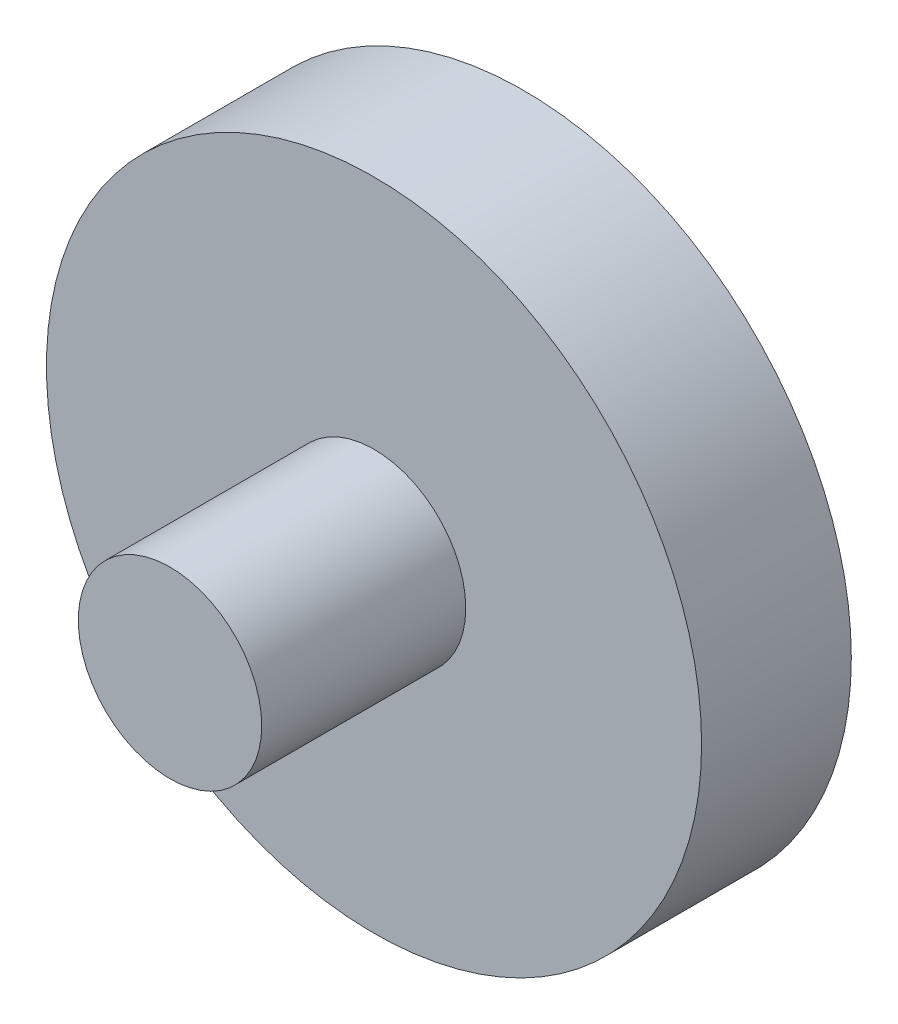
from build123d import *

# Parameters (mm, degrees)
SKETCH1_R           = 17.5
BOSS_EXTRUDE1_DEPTH = 8
SKETCH2_R           = 4.9
BOSS_EXTRUDE2_DEPTH = 10.9


with BuildPart() as part:
    # Sketch1 → Boss-Extrude1 (new body)
    with BuildSketch(Plane.XY):
        Circle(SKETCH1_R)
    extrude(amount=BOSS_EXTRUDE1_DEPTH)

    # Sketch2 → Boss-Extrude2 (add)
    with BuildSketch(Plane.XY.offset(8)):
        Circle(SKETCH2_R)
    extrude(amount=BOSS_EXTRUDE2_DEPTH)


solid = part.part
